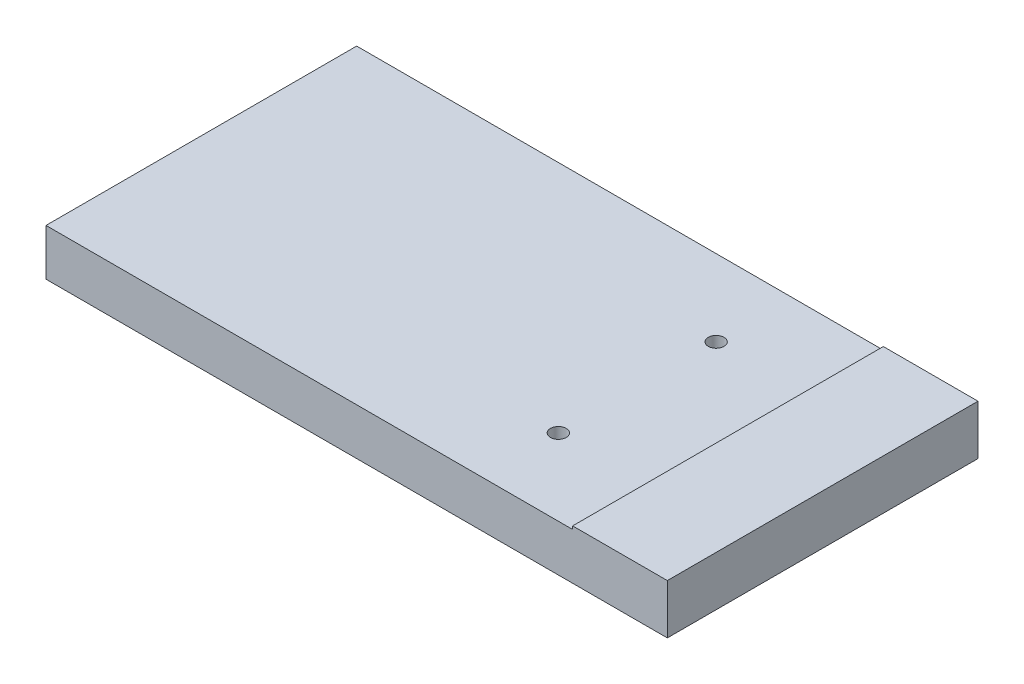
from build123d import *

# Parameters (mm, degrees)
SKETCH1_W           = 2000
SKETCH1_H           = 1000
BOSS_EXTRUDE1_DEPTH = 150
SKETCH2_W           = 304.8
SKETCH2_H           = 1000
BOSS_EXTRUDE2_DEPTH = 10
SKETCH3_R           = 25.4
CUT_EXTRUDE1_DEPTH  = 161


with BuildPart() as part:
    # Sketch1 → Boss-Extrude1 (new body)
    with BuildSketch(Plane(origin=(0, 0, 0), x_dir=(1, 0, 0), z_dir=(0, 1, 0))):
        Rectangle(SKETCH1_W, SKETCH1_H)
    extrude(amount=BOSS_EXTRUDE1_DEPTH)

    # Sketch2 → Boss-Extrude2 (add)
    with BuildSketch(Plane(origin=(0, 150, 0), x_dir=(1, 0, 0), z_dir=(0, 1, 0))):
        with Locations((847.6, 0)):
            Rectangle(SKETCH2_W, SKETCH2_H)
    extrude(amount=BOSS_EXTRUDE2_DEPTH)

    # Sketch3 → Cut-Extrude1 (cut, through all)
    with BuildSketch(Plane.XZ):
        with Locations((403.1, 254)):
            Circle(SKETCH3_R)
        with Locations((403.1, -254)):
            Circle(SKETCH3_R)
    extrude(amount=-CUT_EXTRUDE1_DEPTH, mode=Mode.SUBTRACT)


solid = part.part
